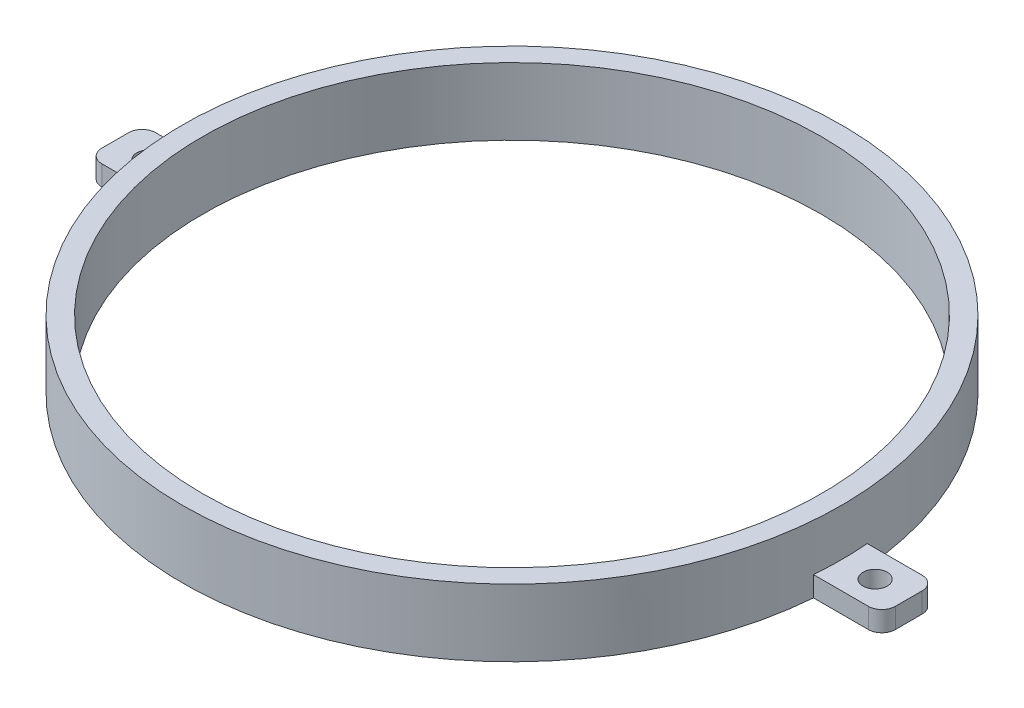
from build123d import *

# Parameters (mm, degrees)
SKETCH1_R           = 49
SKETCH1_R_2         = 46
BOSS_EXTRUDE1_DEPTH = 10
SKETCH2_R           = 1.8
BOSS_EXTRUDE2_DEPTH = 3


with BuildPart() as part:
    # Sketch1 → Boss-Extrude1 (new body)
    with BuildSketch(Plane(origin=(0, 0, 0), x_dir=(1, 0, 0), z_dir=(0, 1, 0))):
        Circle(SKETCH1_R)
        Circle(SKETCH1_R_2, mode=Mode.SUBTRACT)
    extrude(amount=BOSS_EXTRUDE1_DEPTH)

    # Sketch2 → Boss-Extrude2 (add)
    with BuildSketch(Plane(origin=(0, 0, 0), x_dir=(1, 0, 0), z_dir=(0, 1, 0))):
        with BuildLine():
            Line((-46, 0), (-46, 4))
            Line((-46, 4), (-57, 4))
            ThreePointArc((-57, 4), (-58.414213562, 3.414213562), (-59, 2))
            Line((-59, 2), (-59, -2))
            ThreePointArc((-59, -2), (-58.414213562, -3.414213562), (-57, -4))
            Line((-57, -4), (-46, -4))
            Line((-46, -4), (-46, 0))
        make_face()
        with Locations((-54, 0)):
            Circle(SKETCH2_R, mode=Mode.SUBTRACT)
    boss_extrude2 = extrude(amount=BOSS_EXTRUDE2_DEPTH)

    # Mirror1: Boss-Extrude2 across plane
    add(boss_extrude2.mirror(Plane(origin=(0, 0, 0), x_dir=(0, 0, 1), z_dir=(1, 0, 0))))


solid = part.part
